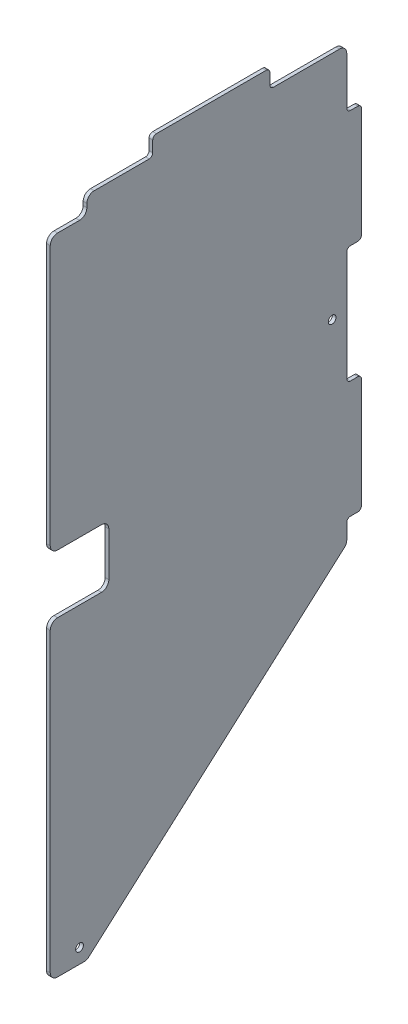
from build123d import *

# Parameters (mm, degrees)
BOSS_EXTRUDE1_DEPTH              = 3.175
SKETCH2_R                        = 3.3655
CUT_EXTRUDE1_DEPTH               = 4.175
SKETCH8_W                        = 50.8
SKETCH8_H                        = 50.8
CUT_EXTRUDE9_DEPTH               = 4.175
FILLET2_R                        = 6.35
SKETCH9_W                        = 101.6
SKETCH9_H                        = 15.875
SKETCH9_W_2                      = 12.7
SKETCH9_H_2                      = 101.6
BOSS_EXTRUDE2_DEPTH              = 3.175
FILLET3_R                        = 3.175
SKETCH10_W                       = 31.75
SKETCH10_H                       = 15.875
CUT_EXTRUDE12_DEPTH              = 4.175
FILLET4_R                        = 6.35
F_17_64_0_26563_DIAMETER_HOLE1_D = 6.747002


with BuildPart() as part:
    # Sketch1 → Boss-Extrude1 (new body)
    with BuildSketch(Plane(origin=(0, 0, 0), x_dir=(0, 0, -1), z_dir=(1, 0, 0))):
        Polygon((0, 0), (0, -574.675), (31.75, -574.675), (257.175, -374.65), (257.175, 0), align=None)
    extrude(amount=BOSS_EXTRUDE1_DEPTH)

    # Sketch2 → Cut-Extrude1 (cut, through all)
    with BuildSketch(Plane(origin=(3.175, 0, 0), x_dir=(0, 0, -1), z_dir=(1, 0, 0))):
        with Locations((25.4, -561.975)):
            Circle(SKETCH2_R)
    extrude(amount=-CUT_EXTRUDE1_DEPTH, mode=Mode.SUBTRACT)

    # Sketch8 → Cut-Extrude9 (cut, through all)
    with BuildSketch(Plane(origin=(3.175, 0, 0), x_dir=(0, 0, -1), z_dir=(1, 0, 0))):
        with Locations((25.4, -279.4)):
            Rectangle(SKETCH8_W, SKETCH8_H)
    extrude(amount=-CUT_EXTRUDE9_DEPTH, mode=Mode.SUBTRACT)

    # Fillet2
    fillet2_edges = [part.edges().sort_by_distance(p)[0] for p in [
        (1.5875, -304.8, 0),
        (1.5875, -254, 0),
        (1.5875, -254, -50.8),
        (1.5875, -304.8, -50.8),
    ]]
    fillet(fillet2_edges, radius=FILLET2_R)

    # Sketch9 → Boss-Extrude2 (add)
    with BuildSketch(Plane(origin=(3.175, 0, 0), x_dir=(0, 0, -1), z_dir=(1, 0, 0))):
        with Locations((139.7, 7.9375)):
            Rectangle(SKETCH9_W, SKETCH9_H)
        with Locations((263.525, -101.6)):
            Rectangle(SKETCH9_W_2, SKETCH9_H_2)
        with Locations((263.525, -304.8)):
            Rectangle(SKETCH9_W_2, SKETCH9_H_2)
    extrude(amount=-BOSS_EXTRUDE2_DEPTH)

    # Fillet3
    fillet3_edges = [part.edges().sort_by_distance(p)[0] for p in [
        (1.5875, 0, -88.9),
        (1.5875, 15.875, -88.9),
        (1.5875, 15.875, -190.5),
        (1.5875, 0, -190.5),
        (1.5875, -152.4, -257.175),
        (1.5875, -50.8, -257.175),
        (1.5875, -50.8, -269.875),
        (1.5875, -152.4, -269.875),
        (1.5875, -355.6, -257.175),
        (1.5875, -254, -257.175),
        (1.5875, -254, -269.875),
        (1.5875, -355.6, -269.875),
    ]]
    fillet(fillet3_edges, radius=FILLET3_R)

    # Sketch10 → Cut-Extrude12 (cut, through all)
    with BuildSketch(Plane(origin=(3.175, 0, 0), x_dir=(0, 0, -1), z_dir=(1, 0, 0))):
        with Locations((15.875, -7.9375)):
            Rectangle(SKETCH10_W, SKETCH10_H)
    extrude(amount=-CUT_EXTRUDE12_DEPTH, mode=Mode.SUBTRACT)

    # Fillet4
    fillet4_edges = [part.edges().sort_by_distance(p)[0] for p in [
        (1.5875, -15.875, 0),
        (1.5875, 0, -31.75),
        (1.5875, -15.875, -31.75),
        (1.5875, 0, -257.175),
        (1.5875, -374.65, -257.175),
        (1.5875, -574.675, -31.75),
        (1.5875, -574.675, 0),
    ]]
    fillet(fillet4_edges, radius=FILLET4_R)

    # 17/64 (0.26563) Diameter Hole1 (through all)
    with Locations(Plane(origin=(3.175, 0, 0), x_dir=(0, 0, -1), z_dir=(1, 0, 0))):
        with Locations((244.475, -200.025)):
            Hole(F_17_64_0_26563_DIAMETER_HOLE1_D / 2)


solid = part.part
